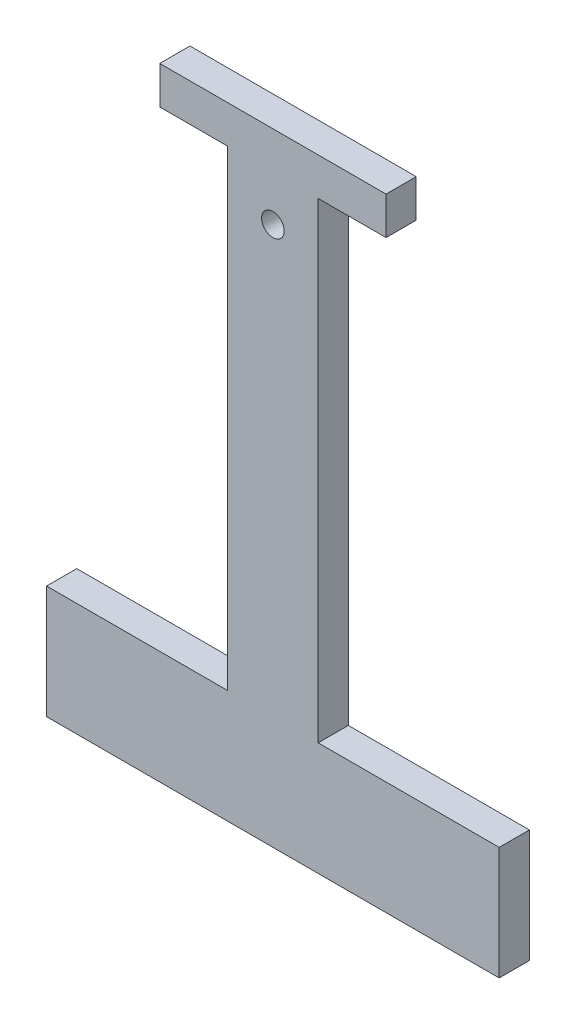
from build123d import *

# Parameters (mm, degrees)
SKETCH_1_R      = 1.5
EXTRUDE_1_DEPTH = 4


with BuildPart() as part:
    # Эскиз1 → Бобышка-Вытянуть1 (new body)
    with BuildSketch(Plane.XY):
        Polygon((5.708165521, 70), (14.708165521, 70), (14.708165521, 75), (-15.291834479, 75), (-15.291834479, 70), (-6.291834479, 70), (-6.291834479, 7.5), (-30.291834479, 7.5), (-30.291834479, -7.5), (29.708165521, -7.5), (29.708165521, 7.5), (5.708165521, 7.5), align=None)
        with Locations((-0.291834479, 64)):
            Circle(SKETCH_1_R, mode=Mode.SUBTRACT)
    extrude(amount=EXTRUDE_1_DEPTH)


solid = part.part
